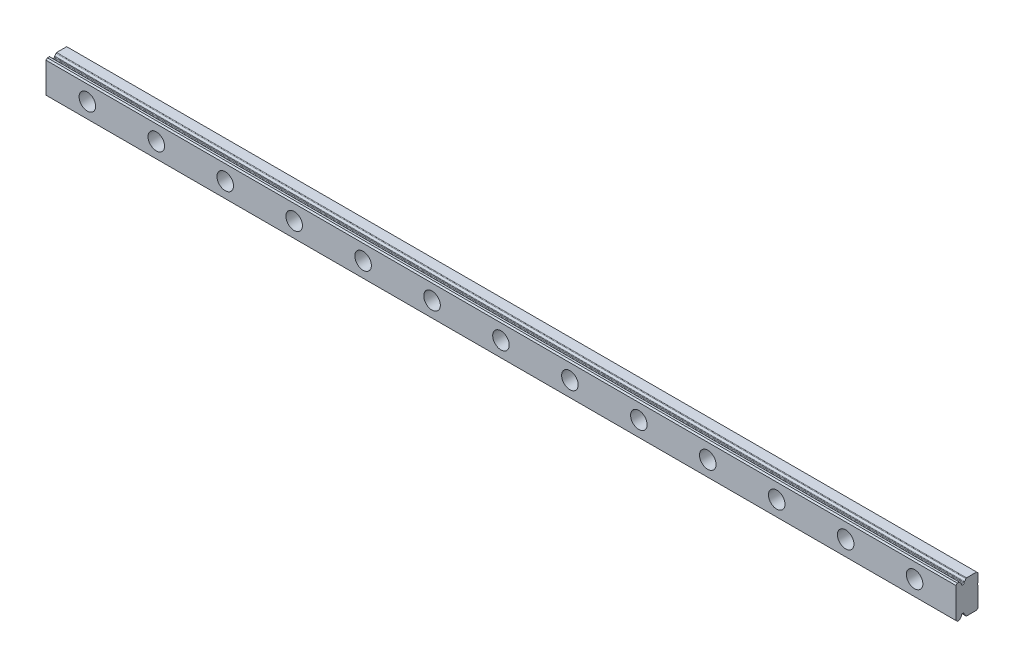
from build123d import *

# Parameters (mm, degrees)
BOSS_EXTRUDE1_DEPTH                              = 330.0000000000001
CUT_EXTRUDE1_DEPTH                               = 331.15148038439605
CUT_EXTRUDE2_DEPTH                               = 331.15148038439605
CUT_EXTRUDE3_DEPTH                               = 331.15148038439605
CUT_EXTRUDE4_DEPTH                               = 331.15148038439605
CUT_EXTRUDE5_DEPTH                               = 331.15148038439605
CBORE_FOR_M3_HEX_HEAD_MACHINE_SCREW1_D           = 3.5
CBORE_FOR_M3_HEX_HEAD_MACHINE_SCREW1_CBORE_D     = 6
CBORE_FOR_M3_HEX_HEAD_MACHINE_SCREW1_CBORE_DEPTH = 4.500000001
CHAMFER1_SIZE                                    = 0.49999999999999817
FILLET1_R                                        = 0.2499999999999934


with BuildPart() as part:
    # Sketch1 → Boss-Extrude1 (new body)
    with BuildSketch(Plane(origin=(315, 0, 0), x_dir=(0, 0, -1), z_dir=(1, 0, 0))):
        Polygon((-6.645656211367382, -5.999999999987301), (-6.086528667804737, -5.9999999999873), (-4.3218662036368185, -5.999999999987301), (-4.142120421, -5.999999999987301), (-0.5, -5.999999999987301), (1.1e-16, -5.999999999987301), (1.1e-16, -5.499999999987301), (1.1e-16, 1.6000000000126995), (1.1e-16, 2.4000000000130934), (1.1e-16, 5.500000000038499), (1.1e-16, 6.000000000012701), (-0.5, 6.000000000012701), (-4.142120421, 6.000000000012701), (-4.321866203637508, 6.000000000012701), (-6.086528667804739, 6.000000000012701), (-6.645656211361536, 6.000000000012701), (-6.8254019940016, 6.0000000000127), (-7.5000000005016, 6.0000000000127), (-8.0000000005016, 5.500000000012699), (-8.0000000005016, -5.4999999999873), (-7.5000000005016, -5.9999999999873), (-6.8254019940016, -5.9999999999873), align=None)
    extrude(amount=-BOSS_EXTRUDE1_DEPTH)

    # Sketch2 → Cut-Extrude1 (cut, through all)
    with BuildSketch(Plane.ZY.offset(15.000000000000124)):
        with BuildLine():
            Line((6.08652866780937, -6.000000000000199), (6.018802044260312, -5.225881150429053))
            Line((6.018802044260312, -5.225881150429053), (6.00733187975836, -5.094776570230831))
            Line((6.00733187975836, -5.094776570230831), (5.975261553557278, -4.728211064330927))
            Line((5.975261553557278, -4.728211064330927), (5.955295672541693, -4.500000000017885))
            Line((5.955295672541693, -4.500000000017885), (5.726212879033703, -4.500000000017885))
            Line((5.726212879033703, -4.500000000017885), (5.273791122033704, -4.500000000017885))
            Line((5.273791122033704, -4.500000000017885), (5.044708328549826, -4.500000000017885))
            Line((5.044708328549826, -4.500000000017885), (5.024742447510704, -4.728211064330986))
            Line((5.024742447510704, -4.728211064330986), (4.994504855310705, -5.073828324330986))
            Line((4.994504855310705, -5.073828324330986), (4.982621846705465, -5.209651734063311))
            ThreePointArc((4.982621846705465, -5.209651734063311), (4.5631182691832715, -5.530313973033924), (4.321866203641435, -6.000000000000199))
            Line((4.321866203641435, -6.000000000000199), (6.08652866780937, -6.000000000000199))
        make_face()
    extrude(amount=-CUT_EXTRUDE1_DEPTH, mode=Mode.SUBTRACT)

    # Sketch3 → Cut-Extrude2 (cut, through all)
    with BuildSketch(Plane.ZY.offset(15.000000000000124)):
        with BuildLine():
            Line((4.63134e-12, 2.4000000000000923), (4.63324e-12, 1.5999999999997847))
            ThreePointArc((4.63324e-12, 1.5999999999997847), (0.20000000000487567, 1.9999999999999392), (4.63134e-12, 2.4000000000000923))
        make_face()
    extrude(amount=-CUT_EXTRUDE2_DEPTH, mode=Mode.SUBTRACT)

    # Sketch4 → Cut-Extrude3 (cut, through all)
    with BuildSketch(Plane.ZY.offset(15.000000000000124)):
        with BuildLine():
            Line((6.007331879761033, 5.0947765702430985), (6.018802044262717, 5.225881150442735))
            Line((6.018802044262717, 5.225881150442735), (6.08652866780937, 6.0000000000127))
            Line((6.08652866780937, 6.0000000000127), (4.3218662036421405, 6.0000000000127))
            ThreePointArc((4.3218662036421405, 6.0000000000127), (4.563118269185973, 5.530313973045934), (4.982621846709898, 5.209651734075363))
            Line((4.982621846709898, 5.209651734075363), (4.994504855315133, 5.0738283243431))
            Line((4.994504855315133, 5.0738283243431), (5.024742447515134, 4.728211064343101))
            Line((5.024742447515134, 4.728211064343101), (5.044708328554257, 4.50000000003))
            Line((5.044708328554257, 4.50000000003), (5.273791122038133, 4.50000000003))
            Line((5.273791122038133, 4.50000000003), (5.7262128790381315, 4.50000000003))
            Line((5.7262128790381315, 4.50000000003), (5.9552956725461215, 4.50000000003))
            Line((5.9552956725461215, 4.50000000003), (5.975261553561033, 4.728211064343099))
            Line((5.975261553561033, 4.728211064343099), (6.007331879761033, 5.0947765702430985))
        make_face()
    extrude(amount=-CUT_EXTRUDE3_DEPTH, mode=Mode.SUBTRACT)

    # Sketch5 → Cut-Extrude4 (cut, through all)
    with BuildSketch(Plane.ZY.offset(15.000000000000124)):
        with BuildLine():
            Line((6.086528667809372, 6.0000000000127), (6.018802044262717, 5.225881150442735))
            ThreePointArc((6.018802044262717, 5.225881150442735), (6.4163451501653705, 5.544826384286438), (6.645656211366141, 6.0000000000127))
            Line((6.645656211366141, 6.0000000000127), (6.086528667809372, 6.0000000000127))
        make_face()
    extrude(amount=-CUT_EXTRUDE4_DEPTH, mode=Mode.SUBTRACT)

    # Sketch6 → Cut-Extrude5 (cut, through all)
    with BuildSketch(Plane.ZY.offset(15.000000000000124)):
        with BuildLine():
            Line((6.08652866780937, -5.999999999987301), (6.645656211368704, -5.999999999987301))
            ThreePointArc((6.645656211368704, -5.999999999987301), (6.416345150166451, -5.544826384259201), (6.018802044260312, -5.225881150416156))
            Line((6.018802044260312, -5.225881150416156), (6.08652866780937, -5.999999999987301))
        make_face()
    extrude(amount=-CUT_EXTRUDE5_DEPTH, mode=Mode.SUBTRACT)

    # CBORE for M3 Hex Head Machine Screw1 (through all)
    with Locations(Plane.XY.offset(8.0000000005016)):
        with Locations((300, 0), (25, 0), (50, 0), (75, 0), (100, 0), (125, 0), (150, 0), (175, 0), (200, 0), (225, 0), (250, 0), (275, 0), (0, 0)):
            CounterBoreHole(CBORE_FOR_M3_HEX_HEAD_MACHINE_SCREW1_D / 2, CBORE_FOR_M3_HEX_HEAD_MACHINE_SCREW1_CBORE_D / 2, CBORE_FOR_M3_HEX_HEAD_MACHINE_SCREW1_CBORE_DEPTH)

    # Chamfer1
    chamfer1_edges = [part.edges().sort_by_distance(p)[0] for p in [
        (149.99999999999994, 6.000000000012701, -1.1e-16),
        (149.99999999999994, -5.999999999987301, -1.1e-16),
    ]]
    chamfer(chamfer1_edges, length=CHAMFER1_SIZE)

    # Fillet1
    fillet1_edges = [part.edges().sort_by_distance(p)[0] for p in [
        (149.99999999999994, 4.50000000003, 5.955295672546116),
        (149.99999999999994, 4.50000000003, 5.044708328554251),
        (149.99999999999994, 5.209651734075363, 4.982621846709892),
        (149.99999999999994, 6.0000000000127, 4.321866203642135),
        (149.99999999999994, 6.0000000000127, 6.645656211366136),
        (149.99999999999994, 5.225881150442735, 6.018802044262712),
        (149.99999999999994, -5.225881150416156, 6.0188020442603065),
        (149.99999999999994, -5.999999999987301, 6.645656211368698),
        (149.99999999999994, -6.000000000000199, 4.32186620364143),
        (149.99999999999994, -5.209651734063311, 4.9826218467054595),
        (149.99999999999994, -4.500000000017885, 5.044708328549821),
        (149.99999999999994, -4.500000000017885, 5.955295672541688),
    ]]
    fillet(fillet1_edges, radius=FILLET1_R)


solid = part.part
